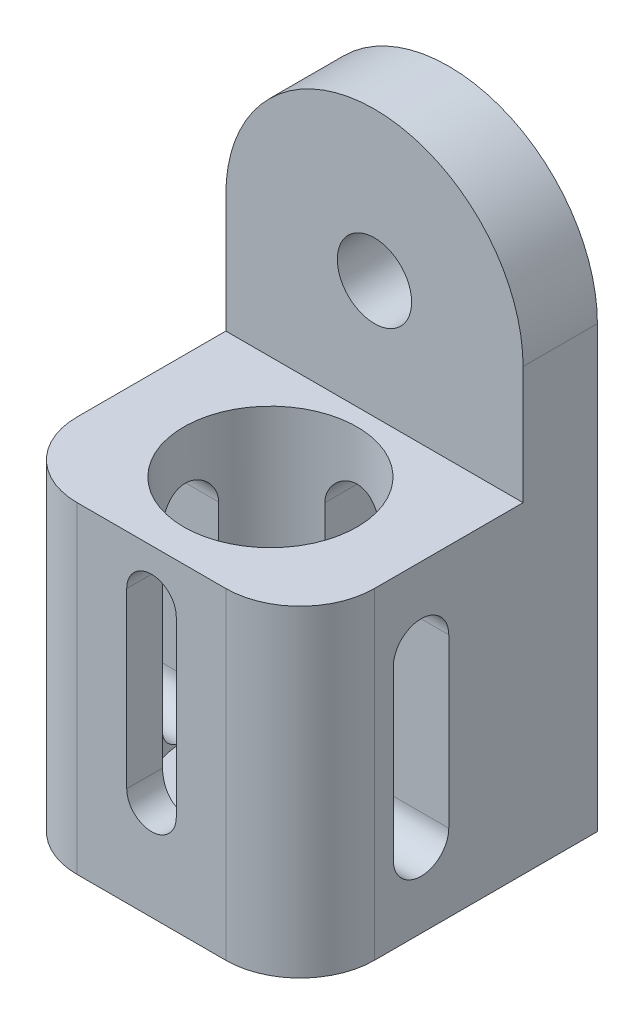
from build123d import *

# Parameters (mm, degrees)
BOSS_EXTRUDE1_DEPTH             = 38.1
BOSS_EXTRUDE2_DEPTH             = 19.05
CUT_EXTRUDE1_DEPTH              = 186.408865419
F_1_4_1_75_DIAMETER_HOLE1_D     = 44.45
F_1_4_1_75_DIAMETER_HOLE1_DEPTH = 69.85
FILLET1_R                       = 19.05
CUT_EXTRUDE2_DEPTH              = 19.05
CUT_EXTRUDE3_DEPTH              = 25.4
F_1_4_0_75_DIAMETER_HOLE1_D     = 19.05


with BuildPart() as part:
    # Sketch1 → Boss-Extrude1 (new, symmetric)
    with BuildSketch(Plane(origin=(0, 0, 0), x_dir=(0, 0, -1), z_dir=(1, 0, 0))):
        Polygon((0, 0), (-76.2, 0), (-76.2, 82.55), (-19.05, 82.55), (-19.05, 112.776), (0, 112.776), align=None)
    extrude(amount=BOSS_EXTRUDE1_DEPTH, both=True)

    # Sketch2 → Boss-Extrude2 (add)
    with BuildSketch(Plane.XY):
        with BuildLine():
            Line((-38.1, 112.776), (38.1, 112.776))
            ThreePointArc((38.1, 112.776), (0, 150.876), (-38.1, 112.776))
        make_face()
    extrude(amount=BOSS_EXTRUDE2_DEPTH)

    # Sketch3 → Cut-Extrude1 (cut, through all)
    with BuildSketch(Plane(origin=(38.1, 0, 0), x_dir=(0, 0, -1), z_dir=(1, 0, 0))):
        with BuildLine():
            Line((-38.1, 62.738), (-38.1, 19.812))
            ThreePointArc((-38.1, 19.812), (-45.212, 12.7), (-52.324, 19.812))
            Line((-52.324, 19.812), (-52.324, 62.738))
            ThreePointArc((-52.324, 62.738), (-45.212, 69.85), (-38.1, 62.738))
        make_face()
    extrude(amount=-CUT_EXTRUDE1_DEPTH, mode=Mode.SUBTRACT)

    # 1_4 _1.75_ Diameter Hole1
    with Locations(Plane(origin=(0, 82.55, 0), x_dir=(1, 0, 0), z_dir=(0, 1, 0))):
        with Locations((0, -45.72)):
            Hole(F_1_4_1_75_DIAMETER_HOLE1_D / 2, depth=F_1_4_1_75_DIAMETER_HOLE1_DEPTH)

    # Fillet1
    fillet1_edges = [part.edges().sort_by_distance(p)[0] for p in [
        (-38.1, 41.275, 76.2),
        (38.1, 41.275, 76.2),
    ]]
    fillet(fillet1_edges, radius=FILLET1_R)

    # Sketch6 → Cut-Extrude2 (cut)
    with BuildSketch(Plane.XY.offset(76.2)):
        with BuildLine():
            Line((-6.35, 25.4), (-6.35, 69.85))
            ThreePointArc((-6.35, 69.85), (0, 76.2), (6.35, 69.85))
            Line((6.35, 69.85), (6.35, 25.4))
            ThreePointArc((6.35, 25.4), (0, 19.05), (-6.35, 25.4))
        make_face()
    extrude(amount=-CUT_EXTRUDE2_DEPTH, mode=Mode.SUBTRACT)

    # Sketch7 → Cut-Extrude3 (cut)
    with BuildSketch(Plane(origin=(0, 0, 0), x_dir=(-1, 0, 0), z_dir=(0, 0, -1))):
        with BuildLine():
            Line((-7.112, 19.812), (-7.112, 62.738))
            ThreePointArc((-7.112, 62.738), (0, 69.85), (7.112, 62.738))
            Line((7.112, 62.738), (7.112, 19.812))
            ThreePointArc((7.112, 19.812), (0, 12.7), (-7.112, 19.812))
        make_face()
    extrude(amount=-CUT_EXTRUDE3_DEPTH, mode=Mode.SUBTRACT)

    # 1_4 _0.75_ Diameter Hole1 (through all)
    with Locations(Plane.XY.offset(19.05)):
        with Locations((0, 112.776)):
            Hole(F_1_4_0_75_DIAMETER_HOLE1_D / 2)


solid = part.part
